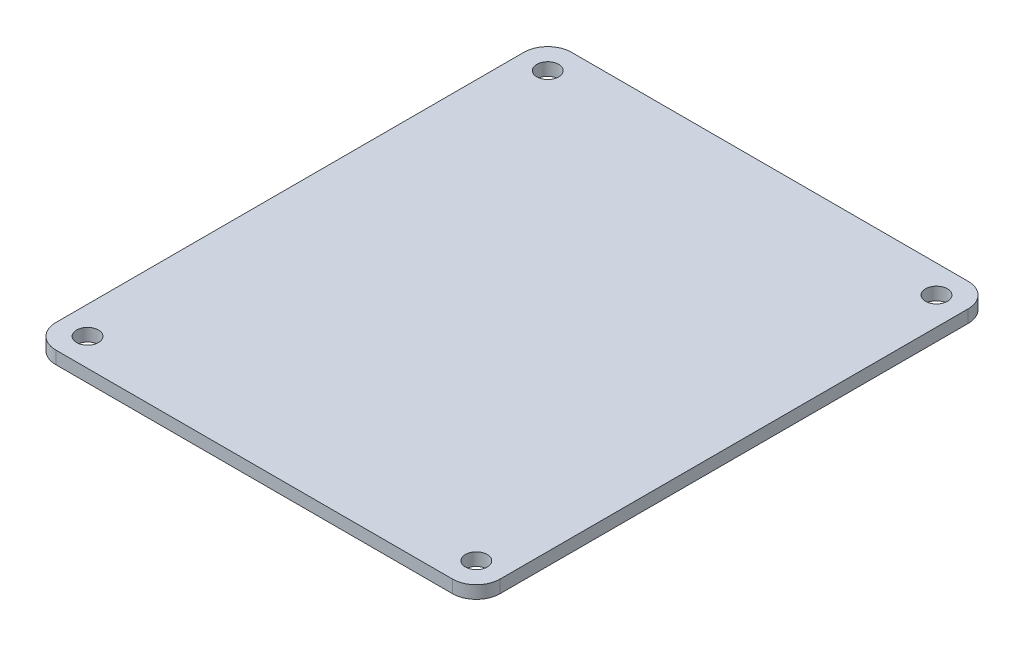
from build123d import *

# Parameters (mm, degrees)
BOSS_EXTRUDE1_DEPTH        = 1.6002
F_2_7_2_7_DIAMETER_HOLE1_D = 2.75


with BuildPart() as part:
    # Sketch1 → Boss-Extrude1 (new body)
    with BuildSketch(Plane(origin=(0, 0, 0), x_dir=(1, 0, 0), z_dir=(0, 1, 0))):
        with BuildLine():
            Line((3, 0), (53, 0))
            ThreePointArc((53, 0), (55.121320344, 0.878679656), (56, 3))
            Line((56, 3), (56, 62))
            ThreePointArc((56, 62), (55.121320344, 64.121320344), (53, 65))
            Line((53, 65), (3, 65))
            ThreePointArc((3, 65), (0.878679656, 64.121320344), (0, 62))
            Line((0, 62), (0, 3))
            ThreePointArc((0, 3), (0.878679656, 0.878679656), (3, 0))
        make_face()
    extrude(amount=BOSS_EXTRUDE1_DEPTH)

    # Ø2.7 (2.7) Diameter Hole1 (through all)
    with Locations(Plane(origin=(0, 1.6002, 0), x_dir=(1, 0, 0), z_dir=(0, 1, 0))):
        with Locations((3.5, 61.5), (3.5, 3.5), (52.5, 61.5), (52.5, 3.5)):
            Hole(F_2_7_2_7_DIAMETER_HOLE1_D / 2)


solid = part.part
